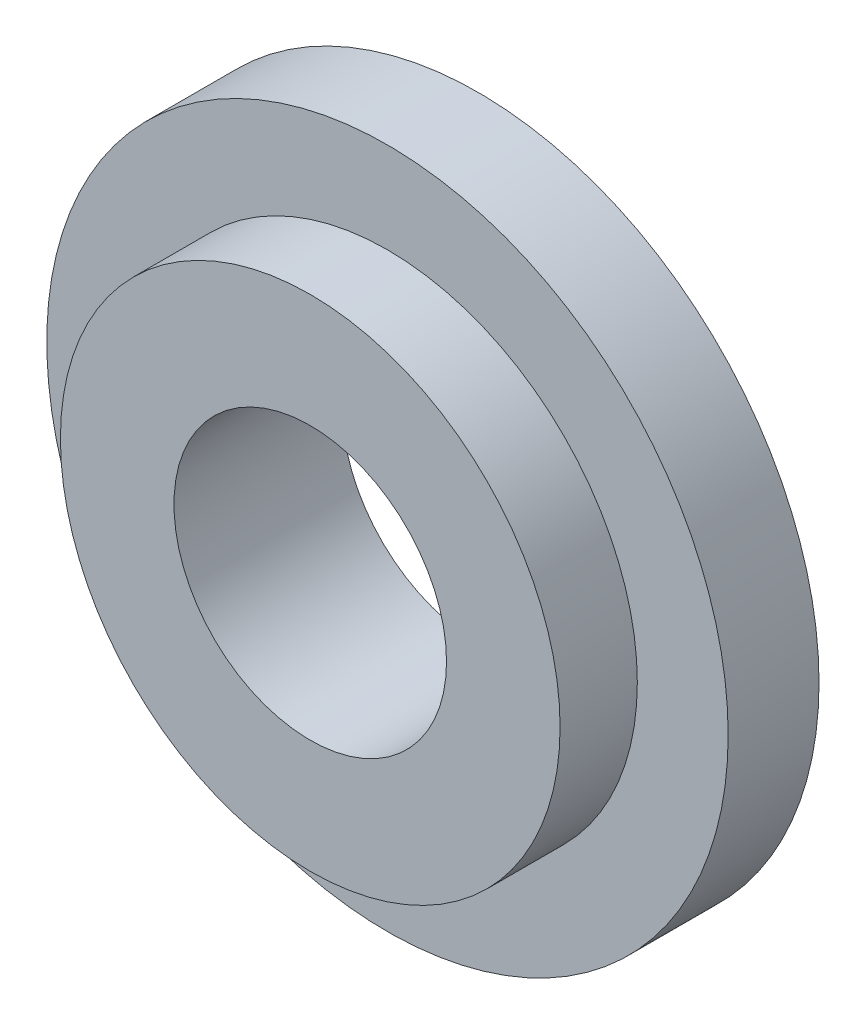
from build123d import *

# Parameters (mm, degrees)
SKETCH1_R           = 3.75
BOSS_EXTRUDE1_DEPTH = 1
SKETCH2_R           = 2.75
BOSS_EXTRUDE2_DEPTH = 0.85
SKETCH3_R           = 1.5
CUT_EXTRUDE1_DEPTH  = 2.85


with BuildPart() as part:
    # Sketch1 → Boss-Extrude1 (new body)
    with BuildSketch(Plane.XY):
        Circle(SKETCH1_R)
    extrude(amount=BOSS_EXTRUDE1_DEPTH)

    # Sketch2 → Boss-Extrude2 (add)
    with BuildSketch(Plane.XY.offset(1)):
        Circle(SKETCH2_R)
    extrude(amount=BOSS_EXTRUDE2_DEPTH)

    # Sketch3 → Cut-Extrude1 (cut, through all)
    with BuildSketch(Plane.XY.offset(1.85)):
        Circle(SKETCH3_R)
    extrude(amount=-CUT_EXTRUDE1_DEPTH, mode=Mode.SUBTRACT)


solid = part.part
